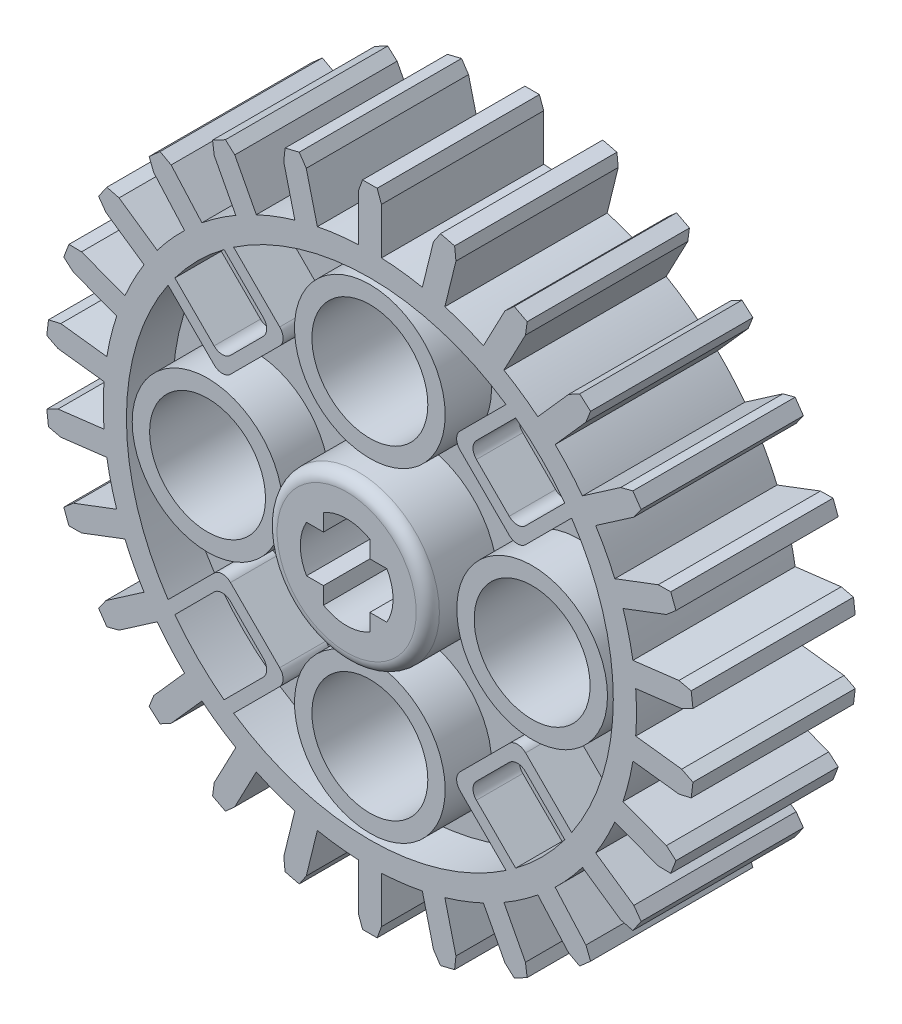
from build123d import *

# Parameters (mm, degrees)
SKETCH1_R                = 11.5
SKETCH1_R_2              = 2
BOSS_EXTRUDE1_DEPTH      = 3.5
SKETCH2_R                = 3.5
SKETCH2_R_2              = 2
BOSS_EXTRUDE2_DEPTH      = 4.5
SKETCH3_R                = 10.5
SKETCH3_R_2              = 3.5
CUT_EXTRUDE2_DEPTH       = 2
BOSS_EXTRUDE3_START      = -5
BOSS_EXTRUDE3_DEPTH      = 7
FILLET1_R                = 0.5
CIRPATTERN1_COUNT        = 4
FILLET1_OF_CIRPATTERN1_R = 0.5
SKETCH6_R                = 3.25
BOSS_EXTRUDE4_DEPTH      = 7
SKETCH7_R                = 2.5
CUT_EXTRUDE3_DEPTH       = 7
CIRPATTERN2_COUNT        = 4
FILLET2_R                = 0.5
BOSS_EXTRUDE5_DEPTH      = 7
CIRPATTERN3_COUNT        = 26


with BuildPart() as part:
    # Sketch1 → Boss-Extrude1 (new body, symmetric)
    with BuildSketch(Plane.XY):
        Circle(SKETCH1_R)
        Circle(SKETCH1_R_2, mode=Mode.SUBTRACT)
        with BuildLine():
            Line((1, -1), (1, -1.732050808))
            ThreePointArc((1, -1.732050808), (1.414213562, -1.414213562), (1.732050808, -1))
            Line((1.732050808, -1), (1, -1))
        make_face()
        with BuildLine():
            ThreePointArc((-1.732050808, -1), (-1.414213562, -1.414213562), (-1, -1.732050808))
            Line((-1, -1.732050808), (-1, -1))
            Line((-1, -1), (-1.732050808, -1))
        make_face()
        with BuildLine():
            Line((-1.732050808, 1), (-1, 1))
            Line((-1, 1), (-1, 1.732050808))
            ThreePointArc((-1, 1.732050808), (-1.414213562, 1.414213562), (-1.732050808, 1))
        make_face()
        with BuildLine():
            Line((1, 1.732050808), (1, 1))
            Line((1, 1), (1.732050808, 1))
            ThreePointArc((1.732050808, 1), (1.414213562, 1.414213562), (1, 1.732050808))
        make_face()
    extrude(amount=BOSS_EXTRUDE1_DEPTH, both=True)

    # Sketch2 → Boss-Extrude2 (add, symmetric)
    with BuildSketch(Plane.XY):
        Circle(SKETCH2_R)
        Circle(SKETCH2_R_2, mode=Mode.SUBTRACT)
        with BuildLine():
            Line((-1.732050808, 1), (-1, 1))
            Line((-1, 1), (-1, 1.732050808))
            ThreePointArc((-1, 1.732050808), (-1.414213562, 1.414213562), (-1.732050808, 1))
        make_face()
        with BuildLine():
            Line((1, 1.732050808), (1, 1))
            Line((1, 1), (1.732050808, 1))
            ThreePointArc((1.732050808, 1), (1.414213562, 1.414213562), (1, 1.732050808))
        make_face()
        with BuildLine():
            Line((1, -1), (1, -1.732050808))
            ThreePointArc((1, -1.732050808), (1.414213562, -1.414213562), (1.732050808, -1))
            Line((1.732050808, -1), (1, -1))
        make_face()
        with BuildLine():
            ThreePointArc((-1.732050808, -1), (-1.414213562, -1.414213562), (-1, -1.732050808))
            Line((-1, -1.732050808), (-1, -1))
            Line((-1, -1), (-1.732050808, -1))
        make_face()
    extrude(amount=BOSS_EXTRUDE2_DEPTH, both=True)

    # Sketch3 → Cut-Extrude2 (cut)
    with BuildSketch(Plane.XY.offset(3.5)):
        Circle(SKETCH3_R)
        Circle(SKETCH3_R_2, mode=Mode.SUBTRACT)
    cut_extrude2 = extrude(amount=-CUT_EXTRUDE2_DEPTH, mode=Mode.SUBTRACT)

    # Mirror1: Cut-Extrude2 across plane
    add(cut_extrude2.mirror(Plane.XY), mode=Mode.SUBTRACT)

    # Sketch4 → Boss-Extrude3 (add)
    with BuildSketch(Plane.XY.offset(1.5).offset(BOSS_EXTRUDE3_START)):
        with BuildLine():
            ThreePointArc((6.287809057, 8.4091294), (6.082916415, 8.558512014), (5.874476306, 8.702903431))
            Line((5.874476306, 8.702903431), (3.535533906, 6.363961031))
            Line((3.535533906, 6.363961031), (6.363961031, 3.535533906))
            Line((6.363961031, 3.535533906), (8.702903431, 5.874476306))
            ThreePointArc((8.702903431, 5.874476306), (8.558512014, 6.082916415), (8.4091294, 6.287809057))
            Line((8.4091294, 6.287809057), (8.051725899, 5.930405555))
            Line((8.051725899, 5.930405555), (6.363961031, 4.242640687))
            Line((6.363961031, 4.242640687), (4.242640687, 6.363961031))
            Line((4.242640687, 6.363961031), (5.930405555, 8.051725899))
            Line((5.930405555, 8.051725899), (6.287809057, 8.4091294))
        make_face()
    boss_extrude3 = extrude(amount=BOSS_EXTRUDE3_DEPTH)

    # Fillet1
    fillet1_edges = [part.edges().sort_by_distance(p)[0] for p in [
        (3.535533906, 6.363961031, 2.5),
        (6.363961031, 4.242640687, 2.5),
        (6.363961031, 3.535533906, 2.5),
        (4.242640687, 6.363961031, 2.5),
        (3.535533906, 6.363961031, -2.5),
        (6.363961031, 3.535533906, -2.5),
        (6.363961031, 4.242640687, -2.5),
        (4.242640687, 6.363961031, -2.5),
    ]]
    fillet(fillet1_edges, radius=FILLET1_R)

    # CirPattern1: Boss-Extrude3 ×4 about axis
    cirpattern1_axis = Axis((0, 0, 0), (0, 0, 1))
    for i in range(1, CIRPATTERN1_COUNT):
        add(boss_extrude3.rotate(cirpattern1_axis, i * 360 / CIRPATTERN1_COUNT))

    # Fillet1 of CirPattern1
    fillet1_of_cirpattern1_edges = [part.edges().sort_by_distance(p)[0] for p in [
        (-6.363961031, 3.535533906, 2.5),
        (-4.242640687, 6.363961031, 2.5),
        (-3.535533906, 6.363961031, 2.5),
        (-6.363961031, 4.242640687, 2.5),
        (-6.363961031, 3.535533906, -2.5),
        (-3.535533906, 6.363961031, -2.5),
        (-4.242640687, 6.363961031, -2.5),
        (-6.363961031, 4.242640687, -2.5),
        (-3.535533906, -6.363961031, 2.5),
        (-6.363961031, -4.242640687, 2.5),
        (-6.363961031, -3.535533906, 2.5),
        (-4.242640687, -6.363961031, 2.5),
        (-3.535533906, -6.363961031, -2.5),
        (-6.363961031, -3.535533906, -2.5),
        (-6.363961031, -4.242640687, -2.5),
        (-4.242640687, -6.363961031, -2.5),
        (6.363961031, -3.535533906, 2.5),
        (4.242640687, -6.363961031, 2.5),
        (3.535533906, -6.363961031, 2.5),
        (6.363961031, -4.242640687, 2.5),
        (6.363961031, -3.535533906, -2.5),
        (3.535533906, -6.363961031, -2.5),
        (4.242640687, -6.363961031, -2.5),
        (6.363961031, -4.242640687, -2.5),
    ]]
    fillet(fillet1_of_cirpattern1_edges, radius=FILLET1_OF_CIRPATTERN1_R)

    # Sketch6 → Boss-Extrude4 (add)
    with BuildSketch(Plane.XY.offset(3.5)):
        with Locations((7, 0)):
            Circle(SKETCH6_R)
    boss_extrude4 = extrude(amount=-BOSS_EXTRUDE4_DEPTH)

    # Sketch7 → Cut-Extrude3 (cut)
    with BuildSketch(Plane.XY.offset(3.5)):
        with Locations((7, 0)):
            Circle(SKETCH7_R)
    cut_extrude3 = extrude(amount=-CUT_EXTRUDE3_DEPTH, mode=Mode.SUBTRACT)

    # CirPattern2: Boss-Extrude4, Cut-Extrude3 ×4 about axis
    cirpattern2_axis = Axis((0, 0, 0), (0, 0, 1))
    for i in range(1, CIRPATTERN2_COUNT):
        add(boss_extrude4.rotate(cirpattern2_axis, i * 360 / CIRPATTERN2_COUNT))
        add(cut_extrude3.rotate(cirpattern2_axis, i * 360 / CIRPATTERN2_COUNT), mode=Mode.SUBTRACT)

    # Fillet2
    fillet2_edges = [part.edges().sort_by_distance(p)[0] for p in [
        (-3.5, 0, -4.5),
        (-3.5, 0, 4.5),
    ]]
    fillet(fillet2_edges, radius=FILLET2_R)

    # Sketch8 → Boss-Extrude5 (add)
    with BuildSketch(Plane.XY.offset(3.5)):
        with BuildLine():
            Line((-0.5, 11.489125293), (-0.5, 13.489125293))
            Line((-0.5, 13.489125293), (-0.314056813, 14))
            Line((-0.314056813, 14), (0.314056813, 14))
            Line((0.314056813, 14), (0.5, 13.489125293))
            Line((0.5, 13.489125293), (0.5, 11.489125293))
            ThreePointArc((0.5, 11.489125293), (0, 11.5), (-0.5, 11.489125293))
        make_face()
    boss_extrude5 = extrude(amount=-BOSS_EXTRUDE5_DEPTH)

    # CirPattern3: Boss-Extrude5 ×26 about axis
    cirpattern3_axis = Axis((0, 0, 0), (0, 0, 1))
    for i in range(1, CIRPATTERN3_COUNT):
        add(boss_extrude5.rotate(cirpattern3_axis, i * 360 / CIRPATTERN3_COUNT))


solid = part.part
